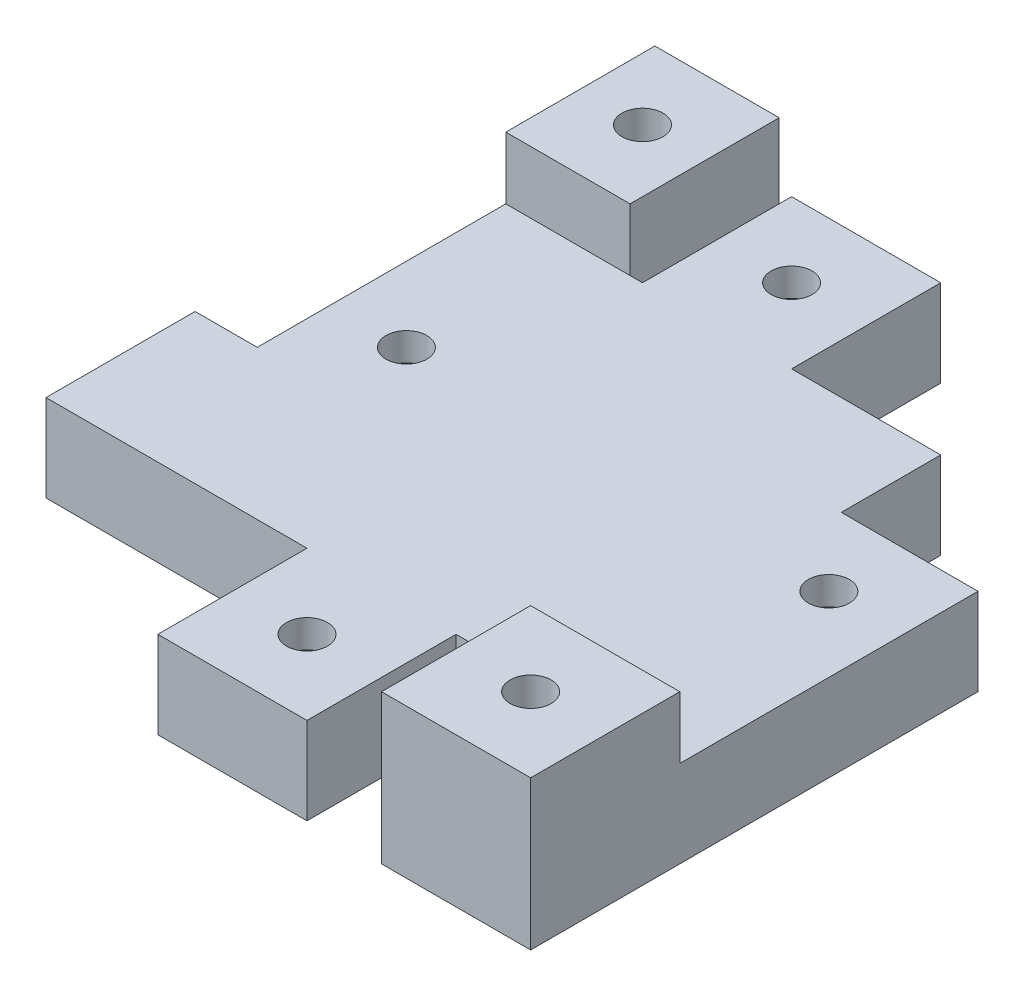
from build123d import *

# Parameters (mm, degrees)
SKETCH1_W             = 12
SKETCH1_H             = 12
SKETCH1_R             = 1.65
BOSS_EXTRUDE1_DEPTH   = 7
BOSS_EXTRUDE1_2_DEPTH = 7
BOSS_EXTRUDE1_3_DEPTH = 7
BOSS_EXTRUDE1_4_DEPTH = 7
CUT_EXTRUDE1_START    = -2.25
CUT_EXTRUDE1_DEPTH    = 2.5
SKETCH3_W             = 22
SKETCH3_H             = 12
BOSS_EXTRUDE2_DEPTH   = 7
SKETCH4_W             = 10
SKETCH4_H             = 12
SKETCH4_R             = 1.65
SKETCH4_W_2           = 12
BOSS_EXTRUDE3_DEPTH   = 7
CUT_EXTRUDE2_START    = -2.25
CUT_EXTRUDE2_DEPTH    = 2.5
SKETCH6_W             = 10
SKETCH6_H             = 12
SKETCH6_R             = 1.65
SKETCH6_W_2           = 12
BOSS_EXTRUDE4_DEPTH   = 5


with BuildPart() as part:
    # Sketch1 → Boss-Extrude1 (new body)
    with BuildSketch(Plane(origin=(0, 0, 0), x_dir=(1, 0, 0), z_dir=(0, 1, 0))):
        with Locations((1, 38)):
            Rectangle(SKETCH1_W, SKETCH1_H)
        with Locations((1, 38)):
            Circle(SKETCH1_R, mode=Mode.SUBTRACT)
    extrude(amount=BOSS_EXTRUDE1_DEPTH)


with BuildPart() as body_2:
    # Sketch1 → Boss-Extrude1 2 (new body)
    with BuildSketch(Plane(origin=(0, 0, 0), x_dir=(1, 0, 0), z_dir=(0, 1, 0))):
        with Locations((6, -6)):
            Rectangle(SKETCH1_W, SKETCH1_H)
        with Locations((6, -6)):
            Circle(SKETCH1_R, mode=Mode.SUBTRACT)
    extrude(amount=BOSS_EXTRUDE1_2_DEPTH)


with BuildPart() as body_3:
    # Sketch1 → Boss-Extrude1 3 (new body)
    with BuildSketch(Plane(origin=(0, 0, 0), x_dir=(1, 0, 0), z_dir=(0, 1, 0))):
        with Locations((-10, 18)):
            Rectangle(SKETCH1_W, SKETCH1_H)
        with Locations((-10, 18)):
            Circle(SKETCH1_R, mode=Mode.SUBTRACT)
    extrude(amount=BOSS_EXTRUDE1_3_DEPTH)


with BuildPart() as body_4:
    # Sketch1 → Boss-Extrude1 4 (new body)
    with BuildSketch(Plane(origin=(0, 0, 0), x_dir=(1, 0, 0), z_dir=(0, 1, 0))):
        with Locations((24, 18)):
            Rectangle(SKETCH1_W, SKETCH1_H)
        with Locations((24, 18)):
            Circle(SKETCH1_R, mode=Mode.SUBTRACT)
    extrude(amount=BOSS_EXTRUDE1_4_DEPTH)


with BuildPart() as cut_extrude1_tool:
    # Sketch2 → Cut-Extrude1 (new body)
    with BuildSketch(Plane(origin=(0, 7, 0), x_dir=(1, 0, 0), z_dir=(0, 1, 0)).offset(CUT_EXTRUDE1_START)):
        Polygon((9.233161507, -6), (7.616580754, -3.2), (4.383419246, -3.2), (2.766838493, -6), (4.383419246, -8.8), (7.616580754, -8.8), align=None)
        Polygon((20.766838493, 18), (22.383419246, 15.2), (25.616580754, 15.2), (27.233161507, 18), (25.616580754, 20.8), (22.383419246, 20.8), align=None)
        Polygon((-2.233161507, 38), (-0.616580754, 35.2), (2.616580754, 35.2), (4.233161507, 38), (2.616580754, 40.8), (-0.616580754, 40.8), align=None)
        Polygon((-13.233161507, 18), (-11.616580754, 15.2), (-8.383419246, 15.2), (-6.766838493, 18), (-8.383419246, 20.8), (-11.616580754, 20.8), align=None)
    extrude(amount=-CUT_EXTRUDE1_DEPTH)


with BuildPart() as part_1:
    add(part.part)

    # Cut-Extrude1: cut by cut_extrude1_tool
    add(cut_extrude1_tool.part, mode=Mode.SUBTRACT)



with BuildPart() as body_2_1:
    add(body_2.part)

    # Cut-Extrude1: cut by cut_extrude1_tool
    add(cut_extrude1_tool.part, mode=Mode.SUBTRACT)


with BuildPart() as body_3_1:
    add(body_3.part)

    # Cut-Extrude1: cut by cut_extrude1_tool
    add(cut_extrude1_tool.part, mode=Mode.SUBTRACT)


with BuildPart() as body_4_1:
    add(body_4.part)

    # Cut-Extrude1: cut by cut_extrude1_tool
    add(cut_extrude1_tool.part, mode=Mode.SUBTRACT)


with BuildPart() as part_2:
    add(part_1.part)

    add(body_2_1.part)  # Boss-Extrude2 merges body 2

    add(body_3_1.part)  # Boss-Extrude2 merges body 3

    add(body_4_1.part)  # Boss-Extrude2 merges body 4
    # Sketch3 → Boss-Extrude2 (add)
    with BuildSketch(Plane(origin=(0, 7, 0), x_dir=(1, 0, 0), z_dir=(0, 1, 0))):
        Polygon((-16, 24), (-4, 24), (18, 24), (19, 24), (19, 32), (-16, 32), align=None)
        with Locations((7, 18)):
            Rectangle(SKETCH3_W, SKETCH3_H)
        Polygon((-21, 12), (-21, 0), (0, 0), (12, 0), (30, 0), (30, 12), (18, 12), (-4, 12), align=None)
    extrude(amount=-BOSS_EXTRUDE2_DEPTH)

    # Sketch4 → Boss-Extrude3 (add)
    with BuildSketch(Plane(origin=(0, 7, 0), x_dir=(1, 0, 0), z_dir=(0, 1, 0))):
        with Locations((-11, 38)):
            Rectangle(SKETCH4_W, SKETCH4_H)
        with Locations((-11, 38)):
            Circle(SKETCH4_R, mode=Mode.SUBTRACT)
        with Locations((24, -6)):
            Rectangle(SKETCH4_W_2, SKETCH4_H)
        with Locations((24, -6)):
            Circle(SKETCH4_R, mode=Mode.SUBTRACT)
    extrude(amount=-BOSS_EXTRUDE3_DEPTH)

    # Sketch5 → Cut-Extrude2 (cut)
    with BuildSketch(Plane(origin=(0, 7, 0), x_dir=(1, 0, 0), z_dir=(0, 1, 0)).offset(CUT_EXTRUDE2_START)):
        Polygon((-7.766838493, 38), (-9.383419246, 40.8), (-12.616580754, 40.8), (-14.233161507, 38), (-12.616580754, 35.2), (-9.383419246, 35.2), align=None)
        Polygon((27.233161507, -6), (25.616580754, -3.2), (22.383419246, -3.2), (20.766838493, -6), (22.383419246, -8.8), (25.616580754, -8.8), align=None)
    extrude(amount=-CUT_EXTRUDE2_DEPTH, mode=Mode.SUBTRACT)

    # Sketch6 → Boss-Extrude4 (add)
    with BuildSketch(Plane(origin=(0, 7, 0), x_dir=(1, 0, 0), z_dir=(0, 1, 0))):
        with Locations((-11, 38)):
            Rectangle(SKETCH6_W, SKETCH6_H)
        with Locations((-11, 38)):
            Circle(SKETCH6_R, mode=Mode.SUBTRACT)
        with Locations((24, -6)):
            Rectangle(SKETCH6_W_2, SKETCH6_H)
        with Locations((24, -6)):
            Circle(SKETCH6_R, mode=Mode.SUBTRACT)
    extrude(amount=BOSS_EXTRUDE4_DEPTH)


solid = part_2.part
